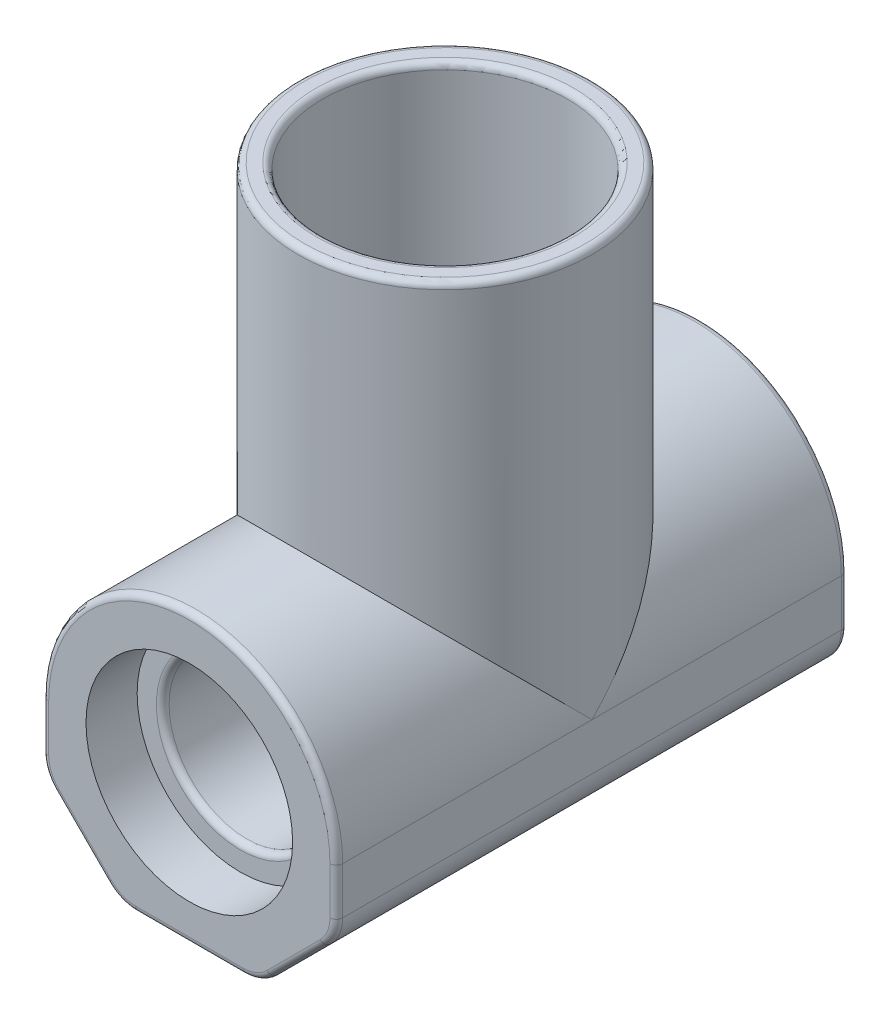
from build123d import *

# Parameters (mm, degrees)
BOSS_EXTRUDE1_DEPTH      = 63.5
BOSS_EXTRUDE1_DEPTH_BACK = 63.5
SKETCH3_R                = 36.5125
BOSS_EXTRUDE2_DEPTH      = 101.6
SKETCH4_R                = 19.304
CUT_EXTRUDE1_DEPTH       = 167.6875
SKETCH5_R                = 25.654
CUT_EXTRUDE2_DEPTH       = 12.7
CUT_EXTRUDE3_START       = -12.7
SKETCH6_R                = 25.654
CUT_EXTRUDE3_DEPTH       = 12.7
SKETCH7_R                = 30.4165
CUT_EXTRUDE4_DEPTH       = 78.834
CHAMFER1_SIZE            = 19.05
FILLET1_R                = 10
FILLET2_R                = 1.5875


with BuildPart() as part:
    # Sketch1 → Boss-Extrude1 (new, two sides: drawn at the far end of the back side and taken through both)
    with BuildSketch(Plane.XY.offset(-BOSS_EXTRUDE1_DEPTH_BACK)):
        with BuildLine():
            Line((-36.5125, 0), (-36.5125, -34.845102384))
            Line((-36.5125, -34.845102384), (36.5125, -34.845102384))
            Line((36.5125, -34.845102384), (36.5125, 0))
            ThreePointArc((36.5125, 0), (0, 36.5125), (-36.5125, 0))
        make_face()
    extrude(amount=BOSS_EXTRUDE1_DEPTH + BOSS_EXTRUDE1_DEPTH_BACK)

    # Sketch3 → Boss-Extrude2 (add)
    with BuildSketch(Plane(origin=(0, 0, 0), x_dir=(1, 0, 0), z_dir=(0, 1, 0))):
        Circle(SKETCH3_R)
    extrude(amount=BOSS_EXTRUDE2_DEPTH)

    # Sketch4 → Cut-Extrude1 (cut, through all)
    with BuildSketch(Plane(origin=(0, 0, -63.5), x_dir=(-1, 0, 0), z_dir=(0, 0, -1))):
        Circle(SKETCH4_R)
    extrude(amount=-CUT_EXTRUDE1_DEPTH, mode=Mode.SUBTRACT)

    # Sketch5 → Cut-Extrude2 (cut)
    with BuildSketch(Plane(origin=(0, 0, -63.5), x_dir=(-1, 0, 0), z_dir=(0, 0, -1))):
        Circle(SKETCH5_R)
    extrude(amount=-CUT_EXTRUDE2_DEPTH, mode=Mode.SUBTRACT)

    # Sketch6 → Cut-Extrude3 (cut)
    with BuildSketch(Plane.XY.offset(63.5).offset(CUT_EXTRUDE3_START)):
        Circle(SKETCH6_R)
    extrude(amount=CUT_EXTRUDE3_DEPTH, mode=Mode.SUBTRACT)

    # Sketch7 → Cut-Extrude4 (cut)
    with BuildSketch(Plane(origin=(0, 101.6, 0), x_dir=(1, 0, 0), z_dir=(0, 1, 0))):
        Circle(SKETCH7_R)
    extrude(amount=-CUT_EXTRUDE4_DEPTH, mode=Mode.SUBTRACT)

    # Chamfer1
    chamfer1_edges = [part.edges().sort_by_distance(p)[0] for p in [
        (36.5125, -34.845102384, 0),
        (-36.5125, -34.845102384, 0),
    ]]
    chamfer(chamfer1_edges, length=CHAMFER1_SIZE)

    # Fillet1
    fillet1_edges = [part.edges().sort_by_distance(p)[0] for p in [
        (36.5125, -15.795102384, 0),
        (17.4625, -34.845102384, 0),
        (-17.4625, -34.845102384, 0),
        (-36.5125, -15.795102384, 0),
    ]]
    fillet(fillet1_edges, radius=FILLET1_R)

    # Fillet2
    fillet2_edges = [part.edges().sort_by_distance(p)[0] for p in [
        (36.5125, -5.82648338, -63.5),
        (35.751295325, -15.479801084, -63.5),
        (26.9875, -25.320102384, -63.5),
        (17.1471987, -34.083897709, -63.5),
        (0, -34.845102384, -63.5),
        (-17.1471987, -34.083897709, -63.5),
        (-26.9875, -25.320102384, -63.5),
        (-35.751295325, -15.479801084, -63.5),
        (-36.5125, -5.82648338, -63.5),
        (36.5125, -5.82648338, 63.5),
        (35.751295325, -15.479801084, 63.5),
        (26.9875, -25.320102384, 63.5),
        (17.1471987, -34.083897709, 63.5),
        (0, -34.845102384, 63.5),
        (-17.1471987, -34.083897709, 63.5),
        (-26.9875, -25.320102384, 63.5),
        (-35.751295325, -15.479801084, 63.5),
        (-36.5125, -5.82648338, 63.5),
        (19.304, 0, -50.8),
        (19.304, 0, 50.8),
        (-30.4165, 101.6, 0),
        (-36.5125, 101.6, 0),
        (0, 36.5125, -63.5),
        (0, 36.5125, 63.5),
    ]]
    fillet(fillet2_edges, radius=FILLET2_R)


solid = part.part
